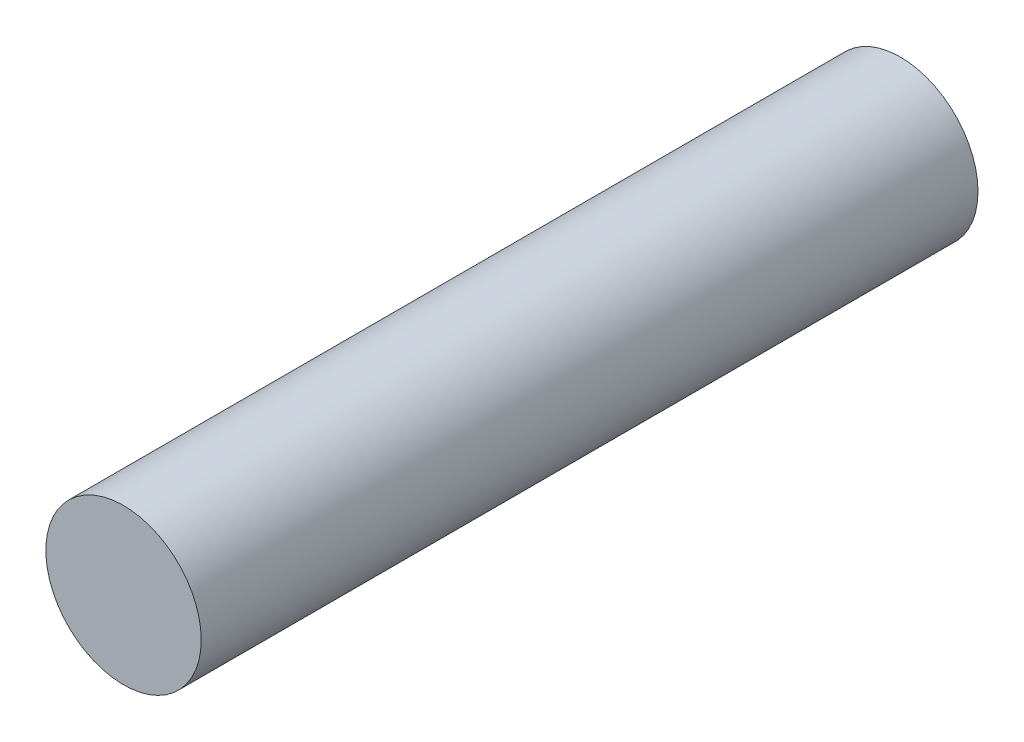
from build123d import *

# Parameters (mm, degrees)
SKETCH1_R           = 10
BOSS_EXTRUDE1_DEPTH = 100


with BuildPart() as part:
    # Sketch1 → Boss-Extrude1 (new body)
    with BuildSketch(Plane.XY):
        Circle(SKETCH1_R)
    extrude(amount=BOSS_EXTRUDE1_DEPTH)


solid = part.part
